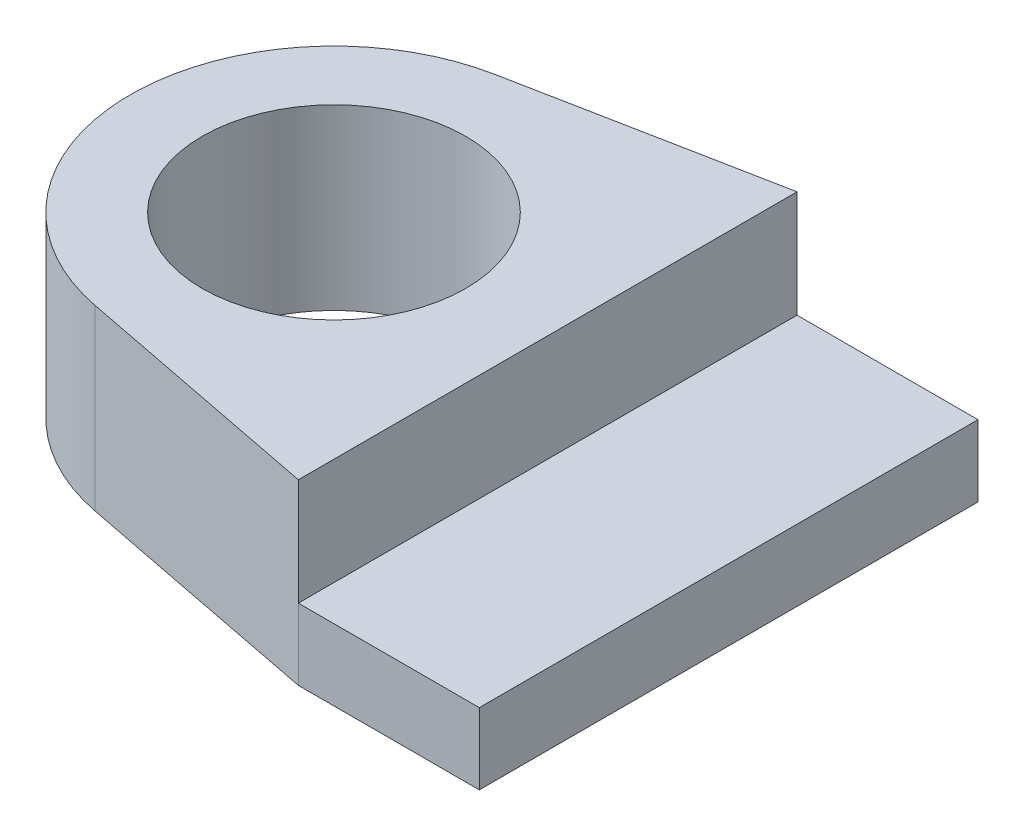
from build123d import *

# Parameters (mm, degrees)
SKETCH1_R           = 18.5
BOSS_EXTRUDE2_DEPTH = 15
BOSS_EXTRUDE3_START = -10
SKETCH1_3_R         = 18.5
BOSS_EXTRUDE3_DEPTH = 10


with BuildPart() as part:
    # Sketch1 → Boss-Extrude2 (new body)
    with BuildSketch(Plane(origin=(0, 0, 0), x_dir=(1, 0, 0), z_dir=(0, 1, 0))):
        with BuildLine():
            Line((-5.482522909, -28.069591065), (30, -35))
            Line((30, -35), (30, 35))
            Line((30, 35), (-5.482522909, 28.069591065))
            ThreePointArc((-5.482522909, 28.069591065), (-28.6, 0), (-5.482522909, -28.069591065))
        make_face()
        Circle(SKETCH1_R, mode=Mode.SUBTRACT)
    extrude(amount=BOSS_EXTRUDE2_DEPTH)

    # Sketch1_3 → Boss-Extrude3 (add)
    with BuildSketch(Plane(origin=(0, 0, 0), x_dir=(1, 0, 0), z_dir=(0, 1, 0)).offset(BOSS_EXTRUDE3_START)):
        with BuildLine():
            Line((-5.482522909, -28.069591065), (30, -35))
            Line((30, -35), (55.4, -35))
            Line((55.4, -35), (55.4, 35))
            Line((55.4, 35), (30, 35))
            Line((30, 35), (-5.482522909, 28.069591065))
            ThreePointArc((-5.482522909, 28.069591065), (-28.6, 0), (-5.482522909, -28.069591065))
        make_face()
        Circle(SKETCH1_3_R, mode=Mode.SUBTRACT)
    extrude(amount=BOSS_EXTRUDE3_DEPTH)


solid = part.part
